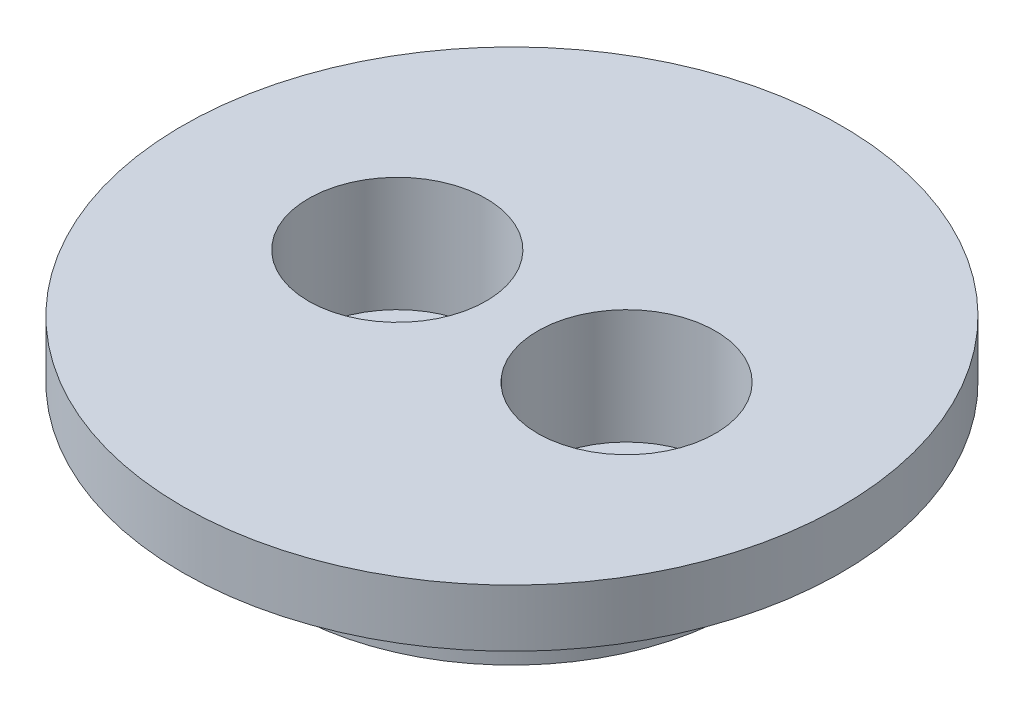
from build123d import *

# Parameters (mm, degrees)
SKETCH1_R           = 7.85
SKETCH1_R_2         = 1.5
BOSS_EXTRUDE1_DEPTH = 3
SKETCH2_R           = 11.5
SKETCH2_R_2         = 1.5
BOSS_EXTRUDE2_DEPTH = 2
SKETCH3_R           = 3.1
CUT_EXTRUDE1_DEPTH  = 4


with BuildPart() as part:
    # Sketch1 → Boss-Extrude1 (new body)
    with BuildSketch(Plane(origin=(0, 35, 0), x_dir=(1, 0, 0), z_dir=(0, 1, 0))):
        Circle(SKETCH1_R)
        with Locations((-4, 0)):
            Circle(SKETCH1_R_2, mode=Mode.SUBTRACT)
        with Locations((4, 0)):
            Circle(SKETCH1_R_2, mode=Mode.SUBTRACT)
    extrude(amount=BOSS_EXTRUDE1_DEPTH)

    # Sketch2 → Boss-Extrude2 (add)
    with BuildSketch(Plane(origin=(0, 38, 0), x_dir=(1, 0, 0), z_dir=(0, 1, 0))):
        Circle(SKETCH2_R)
        with Locations((-4, 0)):
            Circle(SKETCH2_R_2, mode=Mode.SUBTRACT)
        with Locations((4, 0)):
            Circle(SKETCH2_R_2, mode=Mode.SUBTRACT)
    extrude(amount=BOSS_EXTRUDE2_DEPTH)

    # Sketch3 → Cut-Extrude1 (cut)
    with BuildSketch(Plane(origin=(0, 40, 0), x_dir=(1, 0, 0), z_dir=(0, 1, 0))):
        with Locations((-4, 0)):
            Circle(SKETCH3_R)
        with Locations((4, 0)):
            Circle(SKETCH3_R)
    extrude(amount=-CUT_EXTRUDE1_DEPTH, mode=Mode.SUBTRACT)


solid = part.part
